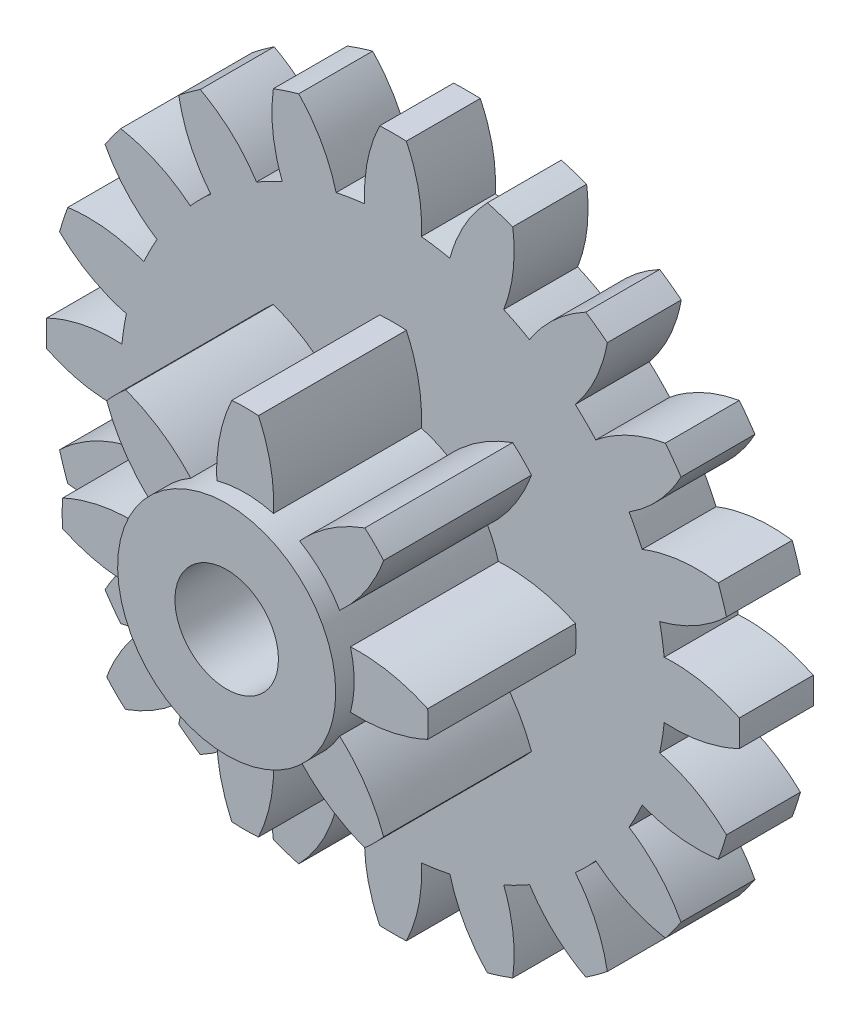
from build123d import *

# Parameters (mm, degrees)
EXTRUDE_1_DEPTH          = 0.5
SKETCH_2_R               = 1.25
EXTRUDE_2_DEPTH          = 0.25
EXTRUDE_3_DEPTH          = 2
SKETCH_4_R               = 0.7
CUT_EXTRUDE_1_DEPTH      = 3.5000001
CUT_EXTRUDE_1_DEPTH_BACK = 1.75
SKETCH_7_R               = 1.475
EXTRUDE_5_DEPTH          = 0.25
SKETCH_8_R               = 0.7
CUT_EXTRUDE_2_DEPTH      = 4.5


with BuildPart() as part:
    # 草图1 → 凸台-拉伸1 (new body, symmetric)
    with BuildSketch(Plane.XY):
        with BuildLine():
            ThreePointArc((-0.38262396, 3.667595282), (-0.57685209, 3.642100756), (-0.76945226, 3.606327699))
            add(Edge.make_bspline(
                [(-1.276290582, 4.510403374), (-0.905965718, 4.123290839), (-0.76945226, 3.606327699)],
                knots=[0, 0, 0, 1, 1, 1], degree=2))
            ThreePointArc((-1.276290582, 4.510403374), (-1.448517161, 4.45807742), (-1.618607815, 4.399177763))
            add(Edge.make_bspline(
                [(-1.618607815, 4.399177763), (-1.690667884, 3.86832565), (-1.497246281, 3.369853086)],
                knots=[0, 0, 0, 1, 1, 1], degree=2))
            ThreePointArc((-1.497246281, 3.369853086), (-1.674089968, 3.285586558), (-1.846209132, 3.192047633))
            add(Edge.make_bspline(
                [(-2.607615769, 3.895253041), (-2.135791542, 3.641523818), (-1.846209132, 3.192047633)],
                knots=[0, 0, 0, 1, 1, 1], degree=2))
            ThreePointArc((-2.607615769, 3.895253041), (-2.75524337, 3.792267161), (-2.8988082, 3.683689356))
            add(Edge.make_bspline(
                [(-2.8988082, 3.683689356), (-2.803299073, 3.156551209), (-2.465307704, 2.742246191)],
                knots=[0, 0, 0, 1, 1, 1], degree=2))
            ThreePointArc((-2.465307704, 2.742246191), (-2.607456256, 2.607456256), (-2.742246191, 2.465307704))
            add(Edge.make_bspline(
                [(-3.683689356, 2.8988082), (-3.156551209, 2.803299073), (-2.742246191, 2.465307704)],
                knots=[0, 0, 0, 1, 1, 1], degree=2))
            ThreePointArc((-3.683689356, 2.8988082), (-3.792267161, 2.75524337), (-3.895253041, 2.607615769))
            add(Edge.make_bspline(
                [(-3.895253041, 2.607615769), (-3.641523818, 2.135791542), (-3.192047633, 1.846209132)],
                knots=[0, 0, 0, 1, 1, 1], degree=2))
            ThreePointArc((-3.192047633, 1.846209132), (-3.285586558, 1.674089968), (-3.369853086, 1.497246281))
            add(Edge.make_bspline(
                [(-4.399177763, 1.618607815), (-3.86832565, 1.690667884), (-3.369853086, 1.497246281)],
                knots=[0, 0, 0, 1, 1, 1], degree=2))
            ThreePointArc((-4.399177763, 1.618607815), (-4.45807742, 1.448517161), (-4.510403374, 1.276290582))
            add(Edge.make_bspline(
                [(-4.510403374, 1.276290582), (-4.123290839, 0.905965718), (-3.606327699, 0.76945226)],
                knots=[0, 0, 0, 1, 1, 1], degree=2))
            ThreePointArc((-3.606327699, 0.76945226), (-3.642100756, 0.57685209), (-3.667595282, 0.38262396))
            add(Edge.make_bspline(
                [(-4.684044, 0.179966819), (-4.201441424, 0.412542342), (-3.667595282, 0.38262396)],
                knots=[0, 0, 0, 1, 1, 1], degree=2))
            ThreePointArc((-4.684044, 0.179966819), (-4.6875, 0), (-4.684044, -0.179966819))
            add(Edge.make_bspline(
                [(-4.684044, -0.179966819), (-4.201441424, -0.412542342), (-3.667595282, -0.38262396)],
                knots=[0, 0, 0, 1, 1, 1], degree=2))
            ThreePointArc((-3.667595282, -0.38262396), (-3.642100756, -0.57685209), (-3.606327699, -0.76945226))
            add(Edge.make_bspline(
                [(-4.510403374, -1.276290582), (-4.123290839, -0.905965718), (-3.606327699, -0.76945226)],
                knots=[0, 0, 0, 1, 1, 1], degree=2))
            ThreePointArc((-4.510403374, -1.276290582), (-4.45807742, -1.448517161), (-4.399177763, -1.618607815))
            add(Edge.make_bspline(
                [(-4.399177763, -1.618607815), (-3.86832565, -1.690667884), (-3.369853086, -1.497246281)],
                knots=[0, 0, 0, 1, 1, 1], degree=2))
            ThreePointArc((-3.369853086, -1.497246281), (-3.285586558, -1.674089968), (-3.192047633, -1.846209132))
            add(Edge.make_bspline(
                [(-3.895253041, -2.607615769), (-3.641523818, -2.135791542), (-3.192047633, -1.846209132)],
                knots=[0, 0, 0, 1, 1, 1], degree=2))
            ThreePointArc((-3.895253041, -2.607615769), (-3.792267161, -2.75524337), (-3.683689356, -2.8988082))
            add(Edge.make_bspline(
                [(-3.683689356, -2.8988082), (-3.156551209, -2.803299073), (-2.742246191, -2.465307704)],
                knots=[0, 0, 0, 1, 1, 1], degree=2))
            ThreePointArc((-2.742246191, -2.465307704), (-2.607456256, -2.607456256), (-2.465307704, -2.742246191))
            add(Edge.make_bspline(
                [(-2.8988082, -3.683689356), (-2.803299073, -3.156551209), (-2.465307704, -2.742246191)],
                knots=[0, 0, 0, 1, 1, 1], degree=2))
            ThreePointArc((-2.8988082, -3.683689356), (-2.75524337, -3.792267161), (-2.607615769, -3.895253041))
            add(Edge.make_bspline(
                [(-2.607615769, -3.895253041), (-2.135791542, -3.641523818), (-1.846209132, -3.192047633)],
                knots=[0, 0, 0, 1, 1, 1], degree=2))
            ThreePointArc((-1.846209132, -3.192047633), (-1.674089968, -3.285586558), (-1.497246281, -3.369853086))
            add(Edge.make_bspline(
                [(-1.618607815, -4.399177763), (-1.690667884, -3.86832565), (-1.497246281, -3.369853086)],
                knots=[0, 0, 0, 1, 1, 1], degree=2))
            ThreePointArc((-1.618607815, -4.399177763), (-1.448517161, -4.45807742), (-1.276290582, -4.510403374))
            add(Edge.make_bspline(
                [(-1.276290582, -4.510403374), (-0.905965718, -4.123290839), (-0.76945226, -3.606327699)],
                knots=[0, 0, 0, 1, 1, 1], degree=2))
            ThreePointArc((-0.76945226, -3.606327699), (-0.57685209, -3.642100756), (-0.38262396, -3.667595282))
            add(Edge.make_bspline(
                [(-0.179966819, -4.684044), (-0.412542342, -4.201441424), (-0.38262396, -3.667595282)],
                knots=[0, 0, 0, 1, 1, 1], degree=2))
            ThreePointArc((-0.179966819, -4.684044), (0, -4.6875), (0.179966819, -4.684044))
            add(Edge.make_bspline(
                [(0.179966819, -4.684044), (0.412542342, -4.201441424), (0.38262396, -3.667595282)],
                knots=[0, 0, 0, 1, 1, 1], degree=2))
            ThreePointArc((0.38262396, -3.667595282), (0.57685209, -3.642100756), (0.76945226, -3.606327699))
            add(Edge.make_bspline(
                [(1.276290582, -4.510403374), (0.905965718, -4.123290839), (0.76945226, -3.606327699)],
                knots=[0, 0, 0, 1, 1, 1], degree=2))
            ThreePointArc((1.276290582, -4.510403374), (1.448517161, -4.45807742), (1.618607815, -4.399177763))
            add(Edge.make_bspline(
                [(1.618607815, -4.399177763), (1.690667884, -3.86832565), (1.497246281, -3.369853086)],
                knots=[0, 0, 0, 1, 1, 1], degree=2))
            ThreePointArc((1.497246281, -3.369853086), (1.674089968, -3.285586558), (1.846209132, -3.192047633))
            add(Edge.make_bspline(
                [(2.607615769, -3.895253041), (2.135791542, -3.641523818), (1.846209132, -3.192047633)],
                knots=[0, 0, 0, 1, 1, 1], degree=2))
            ThreePointArc((2.607615769, -3.895253041), (2.75524337, -3.792267161), (2.8988082, -3.683689356))
            add(Edge.make_bspline(
                [(2.8988082, -3.683689356), (2.803299073, -3.156551209), (2.465307704, -2.742246191)],
                knots=[0, 0, 0, 1, 1, 1], degree=2))
            ThreePointArc((2.465307704, -2.742246191), (2.607456256, -2.607456256), (2.742246191, -2.465307704))
            add(Edge.make_bspline(
                [(3.683689356, -2.8988082), (3.156551209, -2.803299073), (2.742246191, -2.465307704)],
                knots=[0, 0, 0, 1, 1, 1], degree=2))
            ThreePointArc((3.683689356, -2.8988082), (3.792267161, -2.75524337), (3.895253041, -2.607615769))
            add(Edge.make_bspline(
                [(3.895253041, -2.607615769), (3.641523818, -2.135791542), (3.192047633, -1.846209132)],
                knots=[0, 0, 0, 1, 1, 1], degree=2))
            ThreePointArc((3.192047633, -1.846209132), (3.285586558, -1.674089968), (3.369853086, -1.497246281))
            add(Edge.make_bspline(
                [(4.399177763, -1.618607815), (3.86832565, -1.690667884), (3.369853086, -1.497246281)],
                knots=[0, 0, 0, 1, 1, 1], degree=2))
            ThreePointArc((4.399177763, -1.618607815), (4.45807742, -1.448517161), (4.510403374, -1.276290582))
            add(Edge.make_bspline(
                [(4.510403374, -1.276290582), (4.123290839, -0.905965718), (3.606327699, -0.76945226)],
                knots=[0, 0, 0, 1, 1, 1], degree=2))
            ThreePointArc((3.606327699, -0.76945226), (3.642100756, -0.57685209), (3.667595282, -0.38262396))
            add(Edge.make_bspline(
                [(4.684044, -0.179966819), (4.201441424, -0.412542342), (3.667595282, -0.38262396)],
                knots=[0, 0, 0, 1, 1, 1], degree=2))
            ThreePointArc((4.684044, -0.179966819), (4.6875, 0), (4.684044, 0.179966819))
            add(Edge.make_bspline(
                [(4.684044, 0.179966819), (4.201441424, 0.412542342), (3.667595282, 0.38262396)],
                knots=[0, 0, 0, 1, 1, 1], degree=2))
            ThreePointArc((3.667595282, 0.38262396), (3.642100756, 0.57685209), (3.606327699, 0.76945226))
            add(Edge.make_bspline(
                [(4.510403374, 1.276290582), (4.123290839, 0.905965718), (3.606327699, 0.76945226)],
                knots=[0, 0, 0, 1, 1, 1], degree=2))
            ThreePointArc((4.510403374, 1.276290582), (4.45807742, 1.448517161), (4.399177763, 1.618607815))
            add(Edge.make_bspline(
                [(4.399177763, 1.618607815), (3.86832565, 1.690667884), (3.369853086, 1.497246281)],
                knots=[0, 0, 0, 1, 1, 1], degree=2))
            ThreePointArc((3.369853086, 1.497246281), (3.285586558, 1.674089968), (3.192047633, 1.846209132))
            add(Edge.make_bspline(
                [(3.895253041, 2.607615769), (3.641523818, 2.135791542), (3.192047633, 1.846209132)],
                knots=[0, 0, 0, 1, 1, 1], degree=2))
            ThreePointArc((3.895253041, 2.607615769), (3.792267161, 2.75524337), (3.683689356, 2.8988082))
            add(Edge.make_bspline(
                [(3.683689356, 2.8988082), (3.156551209, 2.803299073), (2.742246191, 2.465307704)],
                knots=[0, 0, 0, 1, 1, 1], degree=2))
            ThreePointArc((2.742246191, 2.465307704), (2.607456256, 2.607456256), (2.465307704, 2.742246191))
            add(Edge.make_bspline(
                [(2.8988082, 3.683689356), (2.803299073, 3.156551209), (2.465307704, 2.742246191)],
                knots=[0, 0, 0, 1, 1, 1], degree=2))
            ThreePointArc((2.8988082, 3.683689356), (2.75524337, 3.792267161), (2.607615769, 3.895253041))
            add(Edge.make_bspline(
                [(2.607615769, 3.895253041), (2.135791542, 3.641523818), (1.846209132, 3.192047633)],
                knots=[0, 0, 0, 1, 1, 1], degree=2))
            ThreePointArc((1.846209132, 3.192047633), (1.674089968, 3.285586558), (1.497246281, 3.369853086))
            add(Edge.make_bspline(
                [(1.618607815, 4.399177763), (1.690667884, 3.86832565), (1.497246281, 3.369853086)],
                knots=[0, 0, 0, 1, 1, 1], degree=2))
            ThreePointArc((1.618607815, 4.399177763), (1.448517161, 4.45807742), (1.276290582, 4.510403374))
            add(Edge.make_bspline(
                [(1.276290582, 4.510403374), (0.905965718, 4.123290839), (0.76945226, 3.606327699)],
                knots=[0, 0, 0, 1, 1, 1], degree=2))
            ThreePointArc((0.76945226, 3.606327699), (0.57685209, 3.642100756), (0.38262396, 3.667595282))
            add(Edge.make_bspline(
                [(0.179966819, 4.684044), (0.412542342, 4.201441424), (0.38262396, 3.667595282)],
                knots=[0, 0, 0, 1, 1, 1], degree=2))
            ThreePointArc((0.179966819, 4.684044), (0, 4.6875), (-0.179966819, 4.684044))
            add(Edge.make_bspline(
                [(-0.179966819, 4.684044), (-0.412542342, 4.201441424), (-0.38262396, 3.667595282)],
                knots=[0, 0, 0, 1, 1, 1], degree=2))
        make_face()
    extrude(amount=EXTRUDE_1_DEPTH, both=True)

    # 草图2 → 凸台-拉伸2 (add)
    with BuildSketch(Plane(origin=(0, 0, -0.5), x_dir=(-1, 0, 0), z_dir=(0, 0, -1))):
        Circle(SKETCH_2_R)
    extrude(amount=EXTRUDE_2_DEPTH)

    # 草图3 → 凸台-拉伸3 (add)
    with BuildSketch(Plane.XY.offset(0.5)):
        with BuildLine():
            ThreePointArc((-0.38325, 1.424340001), (-0.564458063, 1.36272231), (-0.736161799, 1.278159147))
            add(Edge.make_bspline(
                [(-1.618265907, 1.872655989), (-1.103724234, 1.683640443), (-0.736161799, 1.278159147)],
                knots=[0, 0, 0, 1, 1, 1], degree=2))
            ThreePointArc((-1.618265907, 1.872655989), (-1.750131484, 1.750047082), (-1.872734032, 1.618175591))
            add(Edge.make_bspline(
                [(-1.872734032, 1.618175591), (-1.683579183, 1.103731297), (-1.278159147, 0.736161799)],
                knots=[0, 0, 0, 1, 1, 1], degree=2))
            ThreePointArc((-1.278159147, 0.736161799), (-1.36272231, 0.564458063), (-1.424340001, 0.38325))
            add(Edge.make_bspline(
                [(-2.468454545, 0.179880952), (-1.970964465, 0.410062684), (-1.424340001, 0.38325)],
                knots=[0, 0, 0, 1, 1, 1], degree=2))
            ThreePointArc((-2.468454545, 0.179880952), (-2.474999999, -5.9682e-05), (-2.468445867, -0.18))
            add(Edge.make_bspline(
                [(-2.468445867, -0.18), (-1.970926142, -0.410014372), (-1.424340001, -0.38325)],
                knots=[0, 0, 0, 1, 1, 1], degree=2))
            ThreePointArc((-1.424340001, -0.38325), (-1.36272231, -0.564458063), (-1.278159147, -0.736161799))
            add(Edge.make_bspline(
                [(-1.872655989, -1.618265907), (-1.683640443, -1.103724234), (-1.278159147, -0.736161799)],
                knots=[0, 0, 0, 1, 1, 1], degree=2))
            ThreePointArc((-1.872655989, -1.618265907), (-1.750047082, -1.750131484), (-1.618175591, -1.872734032))
            add(Edge.make_bspline(
                [(-1.618175591, -1.872734032), (-1.103731297, -1.683579183), (-0.736161799, -1.278159147)],
                knots=[0, 0, 0, 1, 1, 1], degree=2))
            ThreePointArc((-0.736161799, -1.278159147), (-0.564458063, -1.36272231), (-0.38325, -1.424340001))
            add(Edge.make_bspline(
                [(-0.179880952, -2.468454545), (-0.410062684, -1.970964465), (-0.38325, -1.424340001)],
                knots=[0, 0, 0, 1, 1, 1], degree=2))
            ThreePointArc((-0.179880952, -2.468454545), (5.9682e-05, -2.474999999), (0.18, -2.468445867))
            add(Edge.make_bspline(
                [(0.18, -2.468445867), (0.410014372, -1.970926142), (0.38325, -1.424340001)],
                knots=[0, 0, 0, 1, 1, 1], degree=2))
            ThreePointArc((0.38325, -1.424340001), (0.564458063, -1.36272231), (0.736161799, -1.278159147))
            add(Edge.make_bspline(
                [(1.618265907, -1.872655989), (1.103724234, -1.683640443), (0.736161799, -1.278159147)],
                knots=[0, 0, 0, 1, 1, 1], degree=2))
            ThreePointArc((1.618265907, -1.872655989), (1.750131484, -1.750047082), (1.872734032, -1.618175591))
            add(Edge.make_bspline(
                [(1.872734032, -1.618175591), (1.683579183, -1.103731297), (1.278159147, -0.736161799)],
                knots=[0, 0, 0, 1, 1, 1], degree=2))
            ThreePointArc((1.278159147, -0.736161799), (1.36272231, -0.564458063), (1.424340001, -0.38325))
            add(Edge.make_bspline(
                [(2.468454545, -0.179880952), (1.970964465, -0.410062684), (1.424340001, -0.38325)],
                knots=[0, 0, 0, 1, 1, 1], degree=2))
            ThreePointArc((2.468454545, -0.179880952), (2.474999999, 5.9682e-05), (2.468445867, 0.18))
            add(Edge.make_bspline(
                [(2.468445867, 0.18), (1.970926142, 0.410014372), (1.424340001, 0.38325)],
                knots=[0, 0, 0, 1, 1, 1], degree=2))
            ThreePointArc((1.424340001, 0.38325), (1.36272231, 0.564458063), (1.278159147, 0.736161799))
            add(Edge.make_bspline(
                [(1.872655989, 1.618265907), (1.683640443, 1.103724234), (1.278159147, 0.736161799)],
                knots=[0, 0, 0, 1, 1, 1], degree=2))
            ThreePointArc((1.872655989, 1.618265907), (1.750047082, 1.750131484), (1.618175591, 1.872734032))
            add(Edge.make_bspline(
                [(1.618175591, 1.872734032), (1.103731297, 1.683579183), (0.736161799, 1.278159147)],
                knots=[0, 0, 0, 1, 1, 1], degree=2))
            ThreePointArc((0.736161799, 1.278159147), (0.564458063, 1.36272231), (0.38325, 1.424340001))
            add(Edge.make_bspline(
                [(0.179880952, 2.468454545), (0.410062684, 1.970964465), (0.38325, 1.424340001)],
                knots=[0, 0, 0, 1, 1, 1], degree=2))
            ThreePointArc((0.179880952, 2.468454545), (-5.9682e-05, 2.474999999), (-0.18, 2.468445867))
            add(Edge.make_bspline(
                [(-0.18, 2.468445867), (-0.410014372, 1.970926142), (-0.38325, 1.424340001)],
                knots=[0, 0, 0, 1, 1, 1], degree=2))
        make_face()
    extrude(amount=EXTRUDE_3_DEPTH)

    # 草图4 → 切除-拉伸1 (cut, two sides)
    with BuildSketch(Plane.XY) as cut_extrude_1_sk:
        Circle(SKETCH_4_R)
    extrude(amount=CUT_EXTRUDE_1_DEPTH, mode=Mode.SUBTRACT)
    extrude(cut_extrude_1_sk.sketch, amount=-CUT_EXTRUDE_1_DEPTH_BACK, mode=Mode.SUBTRACT)

    # 草图7 → 凸台-拉伸5 (add)
    with BuildSketch(Plane.XY.offset(2.5)):
        Circle(SKETCH_7_R)
    extrude(amount=EXTRUDE_5_DEPTH)

    # 草图8 → 切除-拉伸2 (cut, through all)
    with BuildSketch(Plane.XY.offset(2.75)):
        Circle(SKETCH_8_R)
    extrude(amount=-CUT_EXTRUDE_2_DEPTH, mode=Mode.SUBTRACT)


solid = part.part
